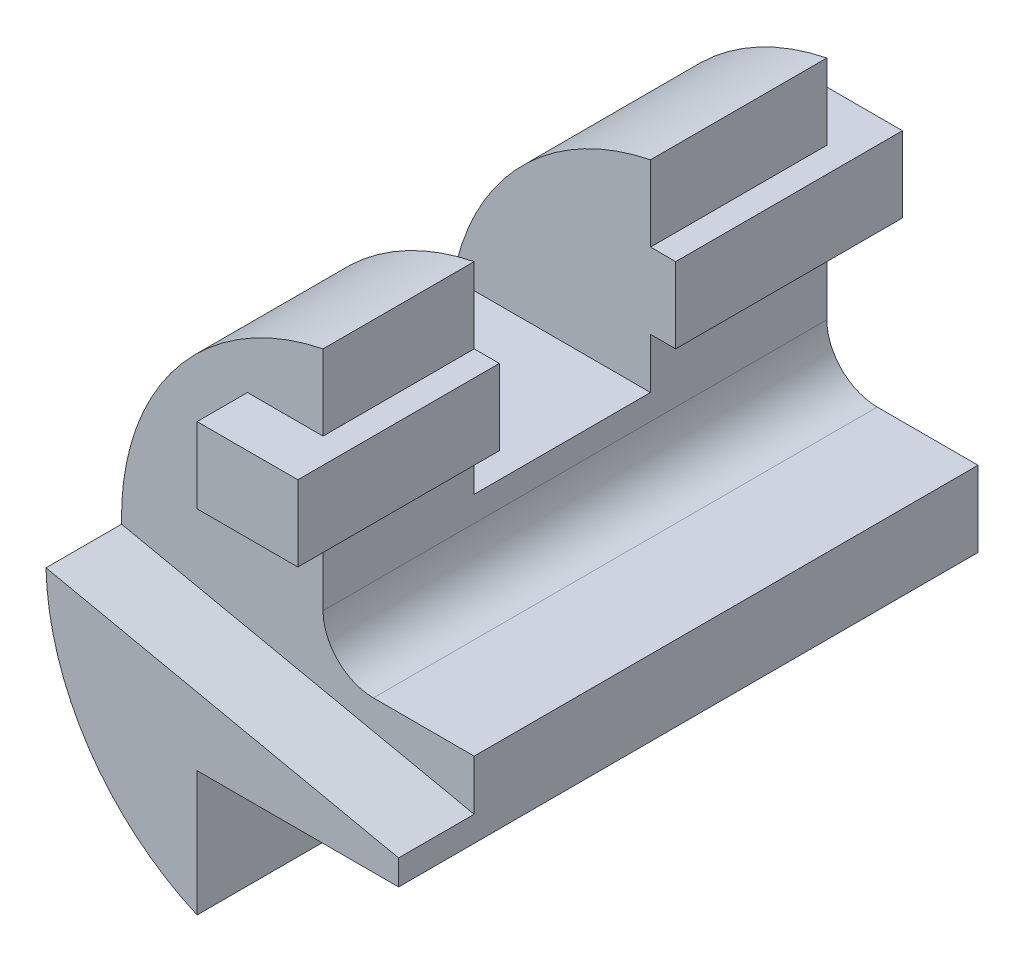
from build123d import *

# Parameters (mm, degrees)
BOSS_EXTRUDE1_DEPTH = 100
CUT_EXTRUDE1_REACH  = 42
SKETCH2_W           = 35
SKETCH2_H           = 40
SKETCH3_W           = 20
SKETCH3_H           = 15
BOSS_EXTRUDE2_DEPTH = 45
SKETCH4_W           = 20
SKETCH4_H           = 15
BOSS_EXTRUDE3_DEPTH = 40
BOSS_EXTRUDE4_DEPTH = 15


with BuildPart() as part:
    # Sketch1 → Boss-Extrude1 (new body)
    with BuildSketch(Plane.XY):
        with BuildLine():
            Line((-20, -45.82575695), (-20, -21.010205144))
            Line((-20, -21.010205144), (20, -21.010205144))
            Line((20, -21.010205144), (20, -6.010205144))
            Line((20, -6.010205144), (0, -6.010205144))
            ThreePointArc((0, -6.010205144), (-7.071067812, -3.081272956), (-10, 3.989794856))
            Line((-10, 3.989794856), (-10, 48.989794856))
            ThreePointArc((-10, 48.989794856), (-49.724211568, 5.244309675), (-20, -45.82575695))
        make_face()
    extrude(amount=BOSS_EXTRUDE1_DEPTH)

    # Sketch2 → Cut-Extrude1 (cut, up to next)
    with BuildSketch(Plane(origin=(-10, 0, 0), x_dir=(0, 0, -1), z_dir=(1, 0, 0)), mode=Mode.PRIVATE) as cut_extrude1_sk1:
        with Locations((-52.5, 28.989794856)):
            Rectangle(SKETCH2_W, SKETCH2_H)
    cut_extrude1_tool1 = extrude(cut_extrude1_sk1.sketch, amount=-CUT_EXTRUDE1_REACH, mode=Mode.PRIVATE) & part.part
    add(cut_extrude1_tool1.solids().sort_by_distance((-10, 28.989795, 52.5))[0], mode=Mode.SUBTRACT)

    # Sketch3 → Boss-Extrude2 (add)
    with BuildSketch(Plane.XY.offset(35)):
        with Locations((-15, 26.489794856)):
            Rectangle(SKETCH3_W, SKETCH3_H)
    extrude(amount=-BOSS_EXTRUDE2_DEPTH)

    # Sketch4 → Boss-Extrude3 (add)
    with BuildSketch(Plane(origin=(0, 0, 70), x_dir=(-1, 0, 0), z_dir=(0, 0, -1))):
        with Locations((15, 26.489794856)):
            Rectangle(SKETCH4_W, SKETCH4_H)
    extrude(amount=-BOSS_EXTRUDE3_DEPTH)

    # Sketch5 → Boss-Extrude4 (add)
    with BuildSketch(Plane.XY.offset(100)):
        with BuildLine():
            Line((20, -16.010205144), (-49.987139252, -1.133979464))
            ThreePointArc((-49.987139252, -1.133979464), (-41.519738184, -27.85877494), (-20, -45.82575695))
            Line((-20, -45.82575695), (-20, -21.010205144))
            Line((-20, -21.010205144), (20, -21.010205144))
            Line((20, -21.010205144), (20, -16.010205144))
        make_face()
    extrude(amount=BOSS_EXTRUDE4_DEPTH)


solid = part.part
